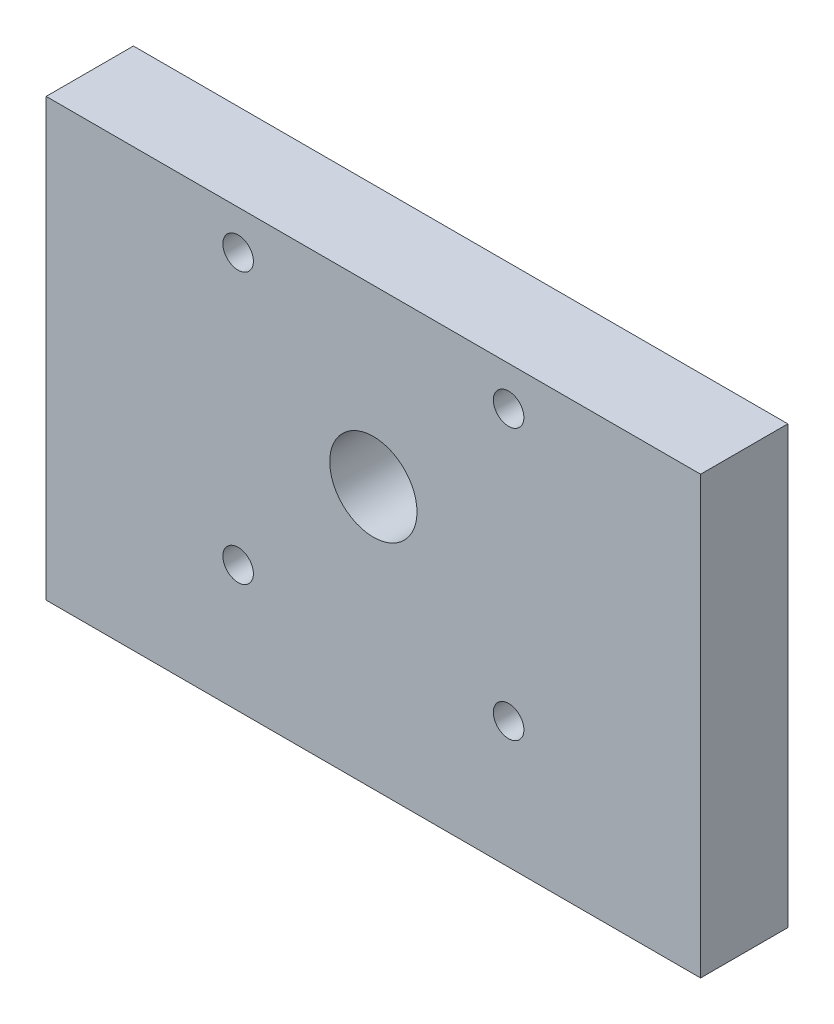
from build123d import *

# Parameters (mm, degrees)
SKETCH1_W                  = 75
SKETCH1_H                  = 40
SKETCH1_R                  = 5
BOSS_EXTRUDE1_DEPTH        = 10
F_3_5_3_5_DIAMETER_HOLE1_D = 3.5
SKETCH4_W                  = 75
SKETCH4_H                  = 10
BOSS_EXTRUDE2_DEPTH        = 10


with BuildPart() as part:
    # Sketch1 → Boss-Extrude1 (new body)
    with BuildSketch(Plane.XY):
        Rectangle(SKETCH1_W, SKETCH1_H)
        Circle(SKETCH1_R, mode=Mode.SUBTRACT)
    extrude(amount=BOSS_EXTRUDE1_DEPTH)

    # Ø3.5 (3.5) Diameter Hole1 (through all)
    with Locations(Plane(origin=(0, 0, 0), x_dir=(-1, 0, 0), z_dir=(0, 0, -1))):
        with Locations((15.5, 15.5), (-15.5, 15.5), (-15.5, -15.5), (15.5, -15.5)):
            Hole(F_3_5_3_5_DIAMETER_HOLE1_D / 2)

    # Sketch4 → Boss-Extrude2 (add)
    with BuildSketch(Plane.XZ.offset(20)):
        with Locations((0, 5)):
            Rectangle(SKETCH4_W, SKETCH4_H)
    extrude(amount=BOSS_EXTRUDE2_DEPTH)


solid = part.part
